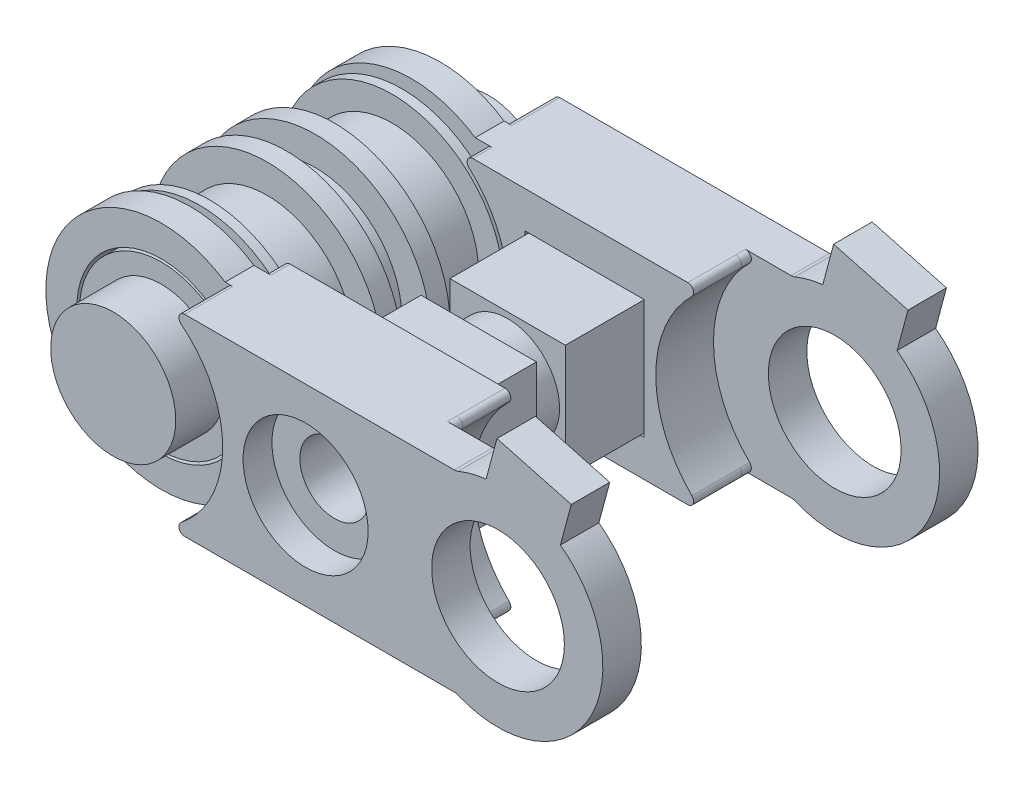
from build123d import *

# Parameters (mm, degrees)
SKETCH_1_R               = 4.5
EXTRUDE_1_DEPTH          = 3
SKETCH_2_R               = 6
EXTRUDE_2_DEPTH          = 1
EXTRUDE_START            = 1.5
SKETCH_3_R               = 4.5
EXTRUDE_3_DEPTH          = 1.5
SKETCH_4_R               = 6.000000000000001
EXTRUDE_4_DEPTH          = 1
EXTRUDE_START_2          = 3
SKETCH_5_R               = 4.5
EXTRUDE_5_DEPTH          = 3
SKETCH_6_R               = 6.000000000000001
EXTRUDE_6_DEPTH          = 1
EXTRUDE_START_3          = 1
SKETCH_7_R               = 6.000000000000001
EXTRUDE_7_DEPTH          = 1
SKETCH_10_R              = 4.25
EXTRUDE_10_DEPTH         = 1.5
SKETCH_11_R              = 3.25
EXTRUDE_11_DEPTH         = 2.5
SKETCH_12_R              = 4.390000000000002
EXTRUDE_12_DEPTH         = 1.5
EXTRUDE_13_DEPTH         = 0.5
FILLET_9_R               = 0.3
SKETCH_14_R              = 3.450000000000003
EXTRUDE_14_DEPTH         = 2
EXTRUDE_15_DEPTH         = 1
SKETCH_16_R              = 1.799999999999999
CUT_EXTRUDE_1_DEPTH      = 33.61828474950821
CUT_EXTRUDE_2_DEPTH      = 2
EXTRUDE_16_DEPTH         = 11.5
SKETCH_19_R              = 1.799999999999999
CUT_EXTRUDE_3_DEPTH      = 30.89903844607716
CUT_EXTRUDE_4_DEPTH      = 0.75
CUT_EXTRUDE_4_DEPTH_BACK = 0.75
SKETCH_20_R              = 2.6999999999999993
SKETCH_21_R              = 3.2500000000000027
CUT_EXTRUDE_5_DEPTH      = 1.5
CUT_EXTRUDE_6_DEPTH      = 1
EXTRUDE_17_DEPTH         = 2
EXTRUDE_18_DEPTH         = 2
SKETCH_26_R              = 6.000000000000001
SKETCH_26_R_2            = 5.800000000000002
CUT_EXTRUDE_8_DEPTH      = 31.240898289165305
SKETCH_27_R              = 6.000000000000001
SKETCH_27_R_2            = 5.8000000000000025
CUT_EXTRUDE_9_DEPTH      = 31.240898289165305
SKETCH_28_R              = 5.800000000000003
SKETCH_28_R_2            = 4.25
CUT_EXTRUDE_10_DEPTH     = 0.5
SKETCH_29_R              = 5.800000000000003
SKETCH_29_R_2            = 4.25
CUT_EXTRUDE_11_DEPTH     = 0.5


with BuildPart() as part:
    # ｽｹｯﾁ1 → ﾎﾞｽ - 押し出し1 (new body)
    with BuildSketch(Plane.XY):
        Circle(SKETCH_1_R)
    extrude(amount=EXTRUDE_1_DEPTH)

    # ｽｹｯﾁ2 → ﾎﾞｽ - 押し出し2 (add)
    with BuildSketch(Plane(origin=(0, 0, 0), x_dir=(-1, 0, 0), z_dir=(0, 0, -1))):
        Circle(SKETCH_2_R)
    extrude(amount=EXTRUDE_2_DEPTH)

    # ｽｹｯﾁ3 → ﾎﾞｽ - 押し出し3 (add)
    with BuildSketch(Plane(origin=(0, 0, -1), x_dir=(-1, 0, 0), z_dir=(0, 0, -1)).offset(EXTRUDE_START)):
        with Locations(Location((0, 0, 0), (0, 0, 180))):
            Circle(SKETCH_3_R)
    extrude(amount=-EXTRUDE_3_DEPTH)

    # ｽｹｯﾁ4 → ﾎﾞｽ - 押し出し4 (add)
    with BuildSketch(Plane(origin=(0, 0, -2.5), x_dir=(-1, 0, 0), z_dir=(0, 0, -1))):
        Circle(SKETCH_4_R)
    extrude(amount=EXTRUDE_4_DEPTH)

    # ｽｹｯﾁ5 → ﾎﾞｽ - 押し出し5 (add)
    with BuildSketch(Plane(origin=(0, 0, -3.5), x_dir=(-1, 0, 0), z_dir=(0, 0, -1)).offset(EXTRUDE_START_2)):
        with Locations(Location((0, 0, 0), (0, 0, 180))):
            Circle(SKETCH_5_R)
    extrude(amount=-EXTRUDE_5_DEPTH)

    # ｽｹｯﾁ6 → ﾎﾞｽ - 押し出し6 (add)
    with BuildSketch(Plane(origin=(0, 0, -6.500000000000001), x_dir=(-1, 0, 0), z_dir=(0, 0, -1))):
        Circle(SKETCH_6_R)
    extrude(amount=EXTRUDE_6_DEPTH)

    # ｽｹｯﾁ7 → ﾎﾞｽ - 押し出し7 (add)
    with BuildSketch(Plane.XY.offset(3).offset(EXTRUDE_START_3)):
        with Locations(Location((0, 0, 0), (0, 0, 180))):
            Circle(SKETCH_7_R)
    extrude(amount=-EXTRUDE_7_DEPTH)

    # ｽｹｯﾁ10 → ﾎﾞｽ - 押し出し10 (add)
    with BuildSketch(Plane.XY.offset(4)):
        Circle(SKETCH_10_R)
    extrude_10 = extrude(amount=EXTRUDE_10_DEPTH)

    # ｽｹｯﾁ11 → ﾎﾞｽ - 押し出し11 (add)
    with BuildSketch(Plane.XY.offset(5.5)):
        Circle(SKETCH_11_R)
    extrude_11 = extrude(amount=EXTRUDE_11_DEPTH)

    # ﾐﾗｰ1: ﾎﾞｽ - 押し出し10, ﾎﾞｽ - 押し出し11 across plane
    add(extrude_10.mirror(Plane.XY.offset(-1.7500000000000002)))
    add(extrude_11.mirror(Plane.XY.offset(-1.7500000000000002)))

    # ｽｹｯﾁ26 → ｶｯﾄ - 押し出し8 (cut, through all)
    with BuildSketch(Plane(origin=(0, 0, 3), x_dir=(-1, 0, 0), z_dir=(0, 0, -1))):
        Circle(SKETCH_26_R)
        Circle(SKETCH_26_R_2, mode=Mode.SUBTRACT)
    extrude(amount=-CUT_EXTRUDE_8_DEPTH, mode=Mode.SUBTRACT)

    # ｽｹｯﾁ27 → ｶｯﾄ - 押し出し9 (cut, through all)
    with BuildSketch(Plane.XY.offset(-6.500000000000001)):
        with Locations(Location((0, 0, 0), (0, 0, 180))):
            Circle(SKETCH_27_R)
        with Locations(Location((0, 0, 0), (0, 0, 180))):
            Circle(SKETCH_27_R_2, mode=Mode.SUBTRACT)
    extrude(amount=-CUT_EXTRUDE_9_DEPTH, mode=Mode.SUBTRACT)

    # ｽｹｯﾁ28 → ｶｯﾄ - 押し出し10 (cut)
    with BuildSketch(Plane(origin=(0, 0, 4), x_dir=(-1, 0, 0), z_dir=(0, 0, -1))):
        Circle(SKETCH_28_R)
        with Locations(Location((-4.3e-16, -4.3e-16, 0), (0, 0, 180))):
            Circle(SKETCH_28_R_2, mode=Mode.SUBTRACT)
    extrude(amount=CUT_EXTRUDE_10_DEPTH, mode=Mode.SUBTRACT)

    # ｽｹｯﾁ29 → ｶｯﾄ - 押し出し11 (cut)
    with BuildSketch(Plane.XY.offset(-7.500000000000001)):
        with Locations(Location((4.3e-16, -4.3e-16, 0), (0, 0, 180))):
            Circle(SKETCH_29_R)
        with Locations(Location((4.3e-16, -4.3e-16, 0), (0, 0, 180))):
            Circle(SKETCH_29_R_2, mode=Mode.SUBTRACT)
    extrude(amount=CUT_EXTRUDE_11_DEPTH, mode=Mode.SUBTRACT)


with BuildPart() as body_2:
    # ｽｹｯﾁ12 → ﾎﾞｽ - 押し出し12 (new body)
    with BuildSketch(Plane.XY.offset(4)):
        with BuildLine():
            Line((3.3166247903554016, 5), (16.167246420652642, 5))
            ThreePointArc((16.167246420652642, 5), (13.700000000000001, 3.57e-15), (16.16724642065264, -5))
            Line((16.16724642065264, -5), (3.3166247903553985, -5.000000000000003))
            ThreePointArc((3.3166247903553985, -5.000000000000003), (-6.000000000000001, 7.3e-16), (3.3166247903554016, 5))
        make_face()
        Circle(SKETCH_12_R, mode=Mode.SUBTRACT)
    extrude(amount=EXTRUDE_12_DEPTH)

    # ｽｹｯﾁ13 → ﾎﾞｽ - 押し出し13 (add)
    with BuildSketch(Plane.XY.offset(5.5)):
        with BuildLine():
            Line((15.366426864718767, 5.000000000000001), (3.71350238992787, 4.999999999999999))
            ThreePointArc((3.71350238992787, 4.999999999999999), (3.4301142319534543, 4.798443648448575), (3.5275172952737197, 4.464607679465777))
            ThreePointArc((3.5275172952737197, 4.464607679465777), (5.69, 3.16e-15), (3.527517295273725, -4.464607679465773))
            ThreePointArc((3.527517295273725, -4.464607679465773), (3.4301142319534588, -4.798443648448569), (3.713502389927875, -4.9999999999999964))
            Line((3.713502389927875, -4.9999999999999964), (15.366426864718758, -4.999999999999996))
            ThreePointArc((15.366426864718758, -4.999999999999996), (15.643997494550977, -4.813818036595895), (15.57704382541336, -4.486363636363631))
            ThreePointArc((15.57704382541336, -4.486363636363631), (13.7, 6.37e-15), (15.577043825413366, 4.486363636363639))
            ThreePointArc((15.577043825413366, 4.486363636363639), (15.643997494550984, 4.813818036595901), (15.366426864718767, 5.000000000000001))
        make_face()
    extrude(amount=EXTRUDE_13_DEPTH)

    # ﾌｨﾚｯﾄ9
    fillet_9_edges = [body_2.edges().sort_by_distance(p)[0] for p in [
        (16.16724642065264, -5.000000000000001, 4.75),
        (16.167246420652642, 5, 4.75),
    ]]
    fillet(fillet_9_edges, radius=FILLET_9_R)

    # ｽｹｯﾁ14 → ﾎﾞｽ - 押し出し14 (add)
    with BuildSketch(Plane.XY.offset(6)):
        with BuildLine():
            Line((3.71350238992787, 5), (17.73008810743677, 5))
            ThreePointArc((17.73008810743677, 5), (17.827318665969592, 5.00954488636839), (17.920837005971492, 5.03781512605042))
            ThreePointArc((17.920837005971492, 5.03781512605042), (25.45, 2.42e-15), (17.920837005971496, -5.037815126050422))
            ThreePointArc((17.920837005971496, -5.037815126050422), (17.827318665969596, -5.009544886368393), (17.730088107436774, -5.000000000000003))
            Line((17.730088107436774, -5.000000000000003), (3.713502389927875, -5.000000000000003))
            ThreePointArc((3.713502389927875, -5.000000000000003), (3.430114231953458, -4.79844364844857), (3.5275172952737246, -4.4646076794657725))
            ThreePointArc((3.5275172952737246, -4.4646076794657725), (5.69, 3.16e-15), (3.52751729527372, 4.464607679465777))
            ThreePointArc((3.52751729527372, 4.464607679465777), (3.4301142319534534, 4.798443648448575), (3.71350238992787, 5))
        make_face()
        with Locations((20, 0)):
            Circle(SKETCH_14_R, mode=Mode.SUBTRACT)
    extrude(amount=EXTRUDE_14_DEPTH)

    # ｽｹｯﾁ15 → ﾎﾞｽ - 押し出し15 (add)
    with BuildSketch(Plane(origin=(0, 0, 4), x_dir=(-1, 0, 0), z_dir=(0, 0, -1))):
        with BuildLine():
            Line((-15.366426864718765, 5), (-4.195235392680607, 5.000000000000001))
            ThreePointArc((-4.195235392680607, 5.000000000000001), (-3.9149294373899135, 4.806904496764971), (-3.9954622787434353, 4.476190476190477))
            ThreePointArc((-3.9954622787434353, 4.476190476190477), (-6.000000000000001, 7.3e-16), (-3.9954622787434353, -4.476190476190477))
            ThreePointArc((-3.9954622787434353, -4.476190476190477), (-3.9149294373899135, -4.806904496764971), (-4.195235392680607, -5.000000000000001))
            Line((-4.195235392680607, -5.000000000000001), (-15.366426864718763, -5))
            ThreePointArc((-15.366426864718763, -5), (-15.643997494550984, -4.813818036595896), (-15.577043825413359, -4.48636363636363))
            ThreePointArc((-15.577043825413359, -4.48636363636363), (-13.700000000000001, 4.2e-15), (-15.577043825413364, 4.486363636363636))
            ThreePointArc((-15.577043825413364, 4.486363636363636), (-15.643997494550984, 4.813818036595898), (-15.366426864718765, 5))
        make_face()
    extrude(amount=EXTRUDE_15_DEPTH)


with BuildPart() as body_3:
    # ﾐﾗｰ2: mirrored copy
    add(body_2.part.mirror(Plane.XY.offset(-1.7500000000000002)))


with BuildPart() as cut_extrude_1_tool:
    # ｽｹｯﾁ16 → ｶｯﾄ - 押し出し1 (new, through all)
    with BuildSketch(Plane.XY.offset(8)):
        with Locations((10, 0)):
            Circle(SKETCH_16_R)
    extrude(amount=-CUT_EXTRUDE_1_DEPTH)


with BuildPart() as body_2_1:
    add(body_2.part)

    # ｶｯﾄ - 押し出し1: cut by cut_extrude_1_tool
    add(cut_extrude_1_tool.part, mode=Mode.SUBTRACT)

    # ｽｹｯﾁ18 → ﾎﾞｽ - 押し出し16 (add)
    with BuildSketch(Plane(origin=(0, 0, 3), x_dir=(-1, 0, 0), z_dir=(0, 0, -1))):
        Polygon((-7.000000000000002, 2.9999999999999996), (-13.000000000000002, 2.9999999999999987), (-13.000000000000002, -2.9999999999999996), (-7.000000000000002, -2.999999999999999), align=None)
    extrude(amount=EXTRUDE_16_DEPTH)

    # ｽｹｯﾁ19 → ｶｯﾄ - 押し出し3 (cut, through all)
    with BuildSketch(Plane.XY.offset(3)):
        with Locations((10, 0)):
            Circle(SKETCH_19_R)
    extrude(amount=-CUT_EXTRUDE_3_DEPTH, mode=Mode.SUBTRACT)

    # ｽｹｯﾁ20 → ｶｯﾄ - 押し出し4 (cut, two sides: drawn at the far end of the back side and taken through both)
    with BuildSketch(Plane.XY.offset(-1.7500000000000002).offset(-CUT_EXTRUDE_4_DEPTH_BACK)):
        Polygon((13.000000000000002, 2.9999999999999987), (7.000000000000002, 2.9999999999999996), (7.000000000000002, -2.999999999999999), (13.000000000000002, -2.9999999999999996), align=None)
        with Locations((10, 0)):
            Circle(SKETCH_20_R, mode=Mode.SUBTRACT)
    extrude(amount=CUT_EXTRUDE_4_DEPTH + CUT_EXTRUDE_4_DEPTH_BACK, mode=Mode.SUBTRACT)

    # ｽｹｯﾁ21 → ｶｯﾄ - 押し出し5 (cut)
    with BuildSketch(Plane.XY.offset(8)):
        with Locations((10, 0)):
            Circle(SKETCH_21_R)
    extrude(amount=-CUT_EXTRUDE_5_DEPTH, mode=Mode.SUBTRACT)

    # ｽｹｯﾁ23 → ﾎﾞｽ - 押し出し17 (add)
    with BuildSketch(Plane.XY.offset(8)):
        Polygon((19.01283786204607, 4.043267356160141), (22.87654116720234, 3.007991175750056), (23.808289729571417, 6.485324150390701), (19.944586424415146, 7.520600330800787), align=None)
    extrude(amount=-EXTRUDE_17_DEPTH)


with BuildPart() as body_3_1:
    add(body_3.part)

    # ｶｯﾄ - 押し出し1: cut by cut_extrude_1_tool
    add(cut_extrude_1_tool.part, mode=Mode.SUBTRACT)

    # ｽｹｯﾁ17 → ｶｯﾄ - 押し出し2 (cut)
    with BuildSketch(Plane.XY.offset(-6.500000000000001)):
        Polygon((13.100000000000001, -3.0999999999999996), (6.900000000000001, -3.1000000000000005), (6.900000000000001, 3.0999999999999996), (13.100000000000001, 3.1000000000000005), align=None)
    extrude(amount=-CUT_EXTRUDE_2_DEPTH, mode=Mode.SUBTRACT)

    # ｽｹｯﾁ22 → ｶｯﾄ - 押し出し6 (cut)
    with BuildSketch(Plane(origin=(0, 0, -11.5), x_dir=(-1, 0, 0), z_dir=(0, 0, -1))):
        Polygon((-11.674315780649914, 2.8999999999999995), (-13.348631561299829, 1e-17), (-11.674315780649913, -2.900000000000001), (-8.325684219350087, -2.9000000000000004), (-6.651368438700171, -8.7e-16), (-8.325684219350087, 2.9), align=None)
    extrude(amount=-CUT_EXTRUDE_6_DEPTH, mode=Mode.SUBTRACT)

    # ｽｹｯﾁ24 → ﾎﾞｽ - 押し出し18 (add)
    with BuildSketch(Plane(origin=(0, 0, -11.5), x_dir=(-1, 0, 0), z_dir=(0, 0, -1))):
        Polygon((-22.87654116720234, 3.007991175750056), (-19.01283786204607, 4.043267356160141), (-19.944586424415146, 7.520600330800787), (-23.808289729571417, 6.485324150390701), align=None)
    extrude(amount=-EXTRUDE_18_DEPTH)


solid = Compound([part.part, body_2_1.part, body_3_1.part])
